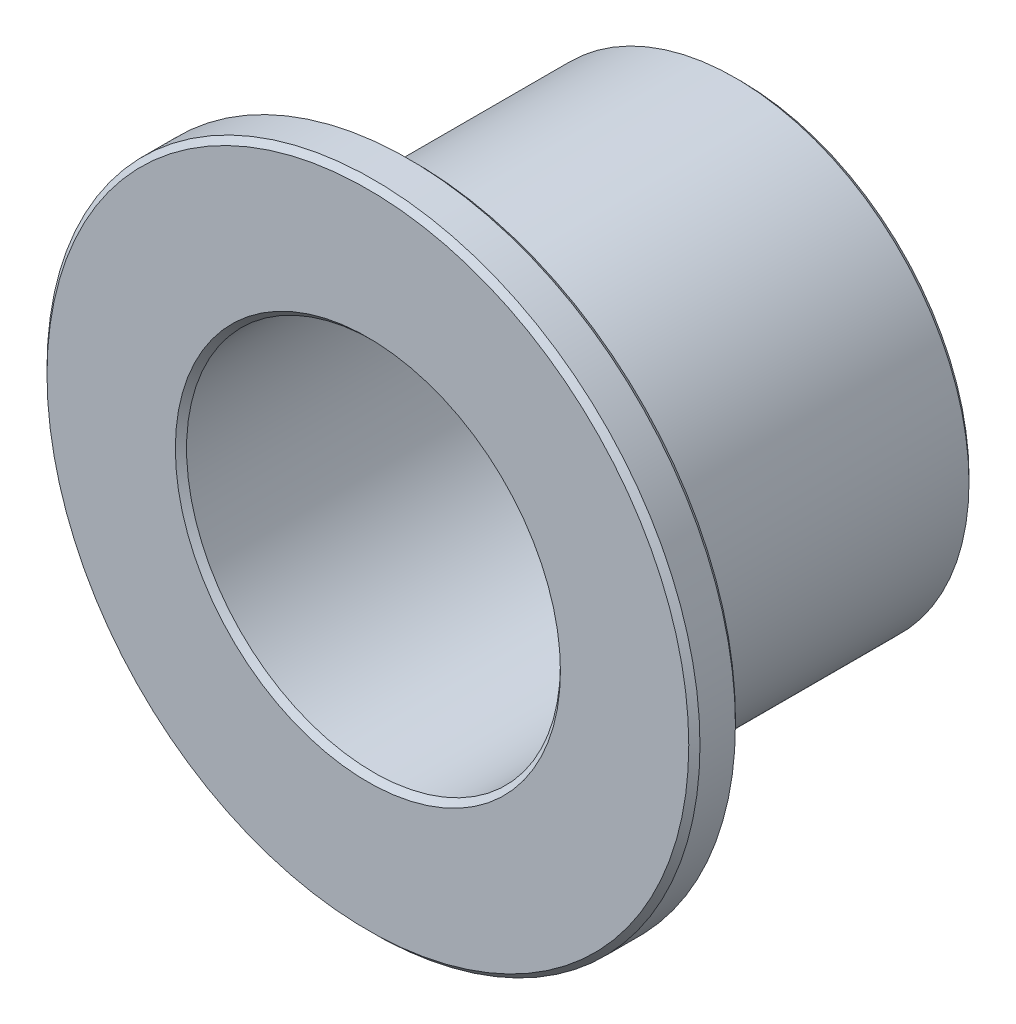
from build123d import *

# Parameters (mm, degrees)
BOSS_EXTRUDE1_START = 6.35
SKETCH3_R           = 11.1125
SKETCH3_R_2         = 6.3627
BOSS_EXTRUDE1_DEPTH = 1.5875
BOSS_EXTRUDE2_START = 4.7625
SKETCH4_R           = 7.9502
SKETCH4_R_2         = 6.3627
BOSS_EXTRUDE2_DEPTH = 11.1125
CHAMFER1_SIZE       = 0.190881


with BuildPart() as part:
    # Sketch3 → Boss-Extrude1 (new body)
    with BuildSketch(Plane.XY.offset(BOSS_EXTRUDE1_START)):
        Circle(SKETCH3_R)
        Circle(SKETCH3_R_2, mode=Mode.SUBTRACT)
    extrude(amount=-BOSS_EXTRUDE1_DEPTH)

    # Sketch4 → Boss-Extrude2 (add)
    with BuildSketch(Plane.XY.offset(BOSS_EXTRUDE2_START)):
        Circle(SKETCH4_R)
        Circle(SKETCH4_R_2, mode=Mode.SUBTRACT)
    extrude(amount=-BOSS_EXTRUDE2_DEPTH)

    # Chamfer1
    chamfer1_edges = [part.edges().sort_by_distance(p)[0] for p in [
        (-6.3627, 0, -6.35),
        (-7.9502, 0, 4.7625),
        (-11.1125, 0, 6.35),
        (-11.1125, 0, 4.7625),
        (-6.3627, 0, 6.35),
        (-7.9502, 0, -6.35),
    ]]
    chamfer(chamfer1_edges, length=CHAMFER1_SIZE)


solid = part.part
